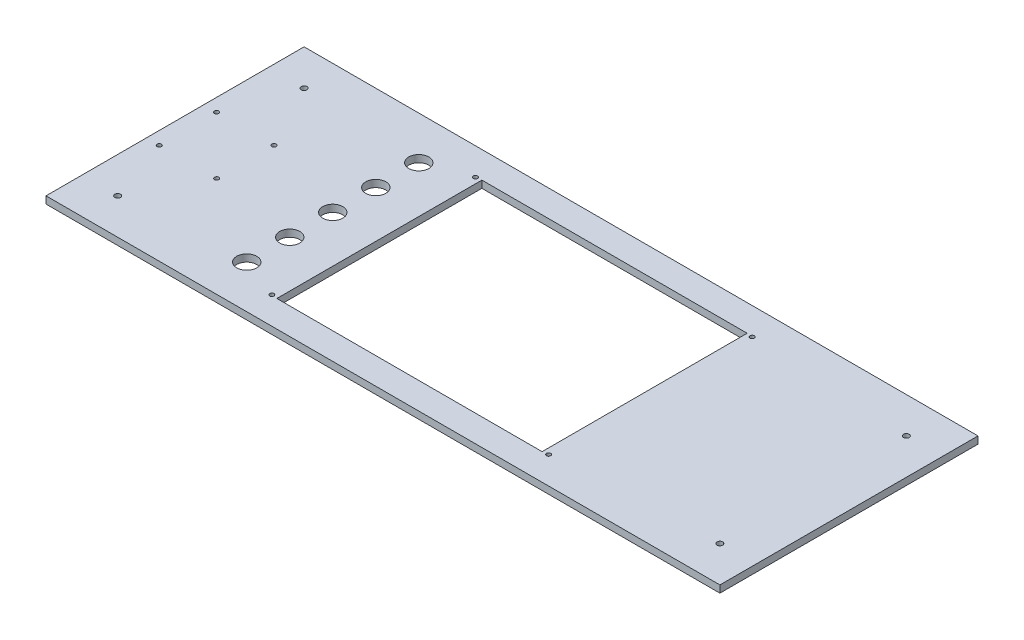
from build123d import *

# Parameters (mm, degrees)
SKETCH_1_W      = 470
SKETCH_1_H      = 180
SKETCH_1_R      = 1.5
SKETCH_1_R_2    = 7
SKETCH_1_R_3    = 2
SKETCH_1_W_2    = 185
SKETCH_1_H_2    = 143
EXTRUDE_1_DEPTH = 5


with BuildPart() as part:
    # 草图1 → 凸台-拉伸1 (new body)
    with BuildSketch(Plane(origin=(0, 0, 0), x_dir=(1, 0, 0), z_dir=(0, 1, 0))):
        with Locations((0, 15)):
            Rectangle(SKETCH_1_W, SKETCH_1_H)
        with Locations((-96.5, 86)):
            Circle(SKETCH_1_R, mode=Mode.SUBTRACT)
        with Locations((96.5, 86)):
            Circle(SKETCH_1_R, mode=Mode.SUBTRACT)
        with Locations((96.5, -56)):
            Circle(SKETCH_1_R, mode=Mode.SUBTRACT)
        with Locations((-96.5, -56)):
            Circle(SKETCH_1_R, mode=Mode.SUBTRACT)
        with Locations((-125, 75)):
            Circle(SKETCH_1_R_2, mode=Mode.SUBTRACT)
        with Locations((-125, 45)):
            Circle(SKETCH_1_R_2, mode=Mode.SUBTRACT)
        with Locations((-125, 15)):
            Circle(SKETCH_1_R_2, mode=Mode.SUBTRACT)
        with Locations((-125, -15)):
            Circle(SKETCH_1_R_2, mode=Mode.SUBTRACT)
        with Locations((-125, -45)):
            Circle(SKETCH_1_R_2, mode=Mode.SUBTRACT)
        with Locations((-226, 35)):
            Circle(SKETCH_1_R, mode=Mode.SUBTRACT)
        with Locations((-186, 35)):
            Circle(SKETCH_1_R, mode=Mode.SUBTRACT)
        with Locations((-186, -5)):
            Circle(SKETCH_1_R, mode=Mode.SUBTRACT)
        with Locations((-226, -5)):
            Circle(SKETCH_1_R, mode=Mode.SUBTRACT)
        with Locations((-210, -50)):
            Circle(SKETCH_1_R_3, mode=Mode.SUBTRACT)
        with Locations((210, -50)):
            Circle(SKETCH_1_R_3, mode=Mode.SUBTRACT)
        with Locations((-210, 80)):
            Circle(SKETCH_1_R_3, mode=Mode.SUBTRACT)
        with Locations((210, 80)):
            Circle(SKETCH_1_R_3, mode=Mode.SUBTRACT)
        with Locations((0, 15)):
            Rectangle(SKETCH_1_W_2, SKETCH_1_H_2, mode=Mode.SUBTRACT)
    extrude(amount=EXTRUDE_1_DEPTH)


solid = part.part
